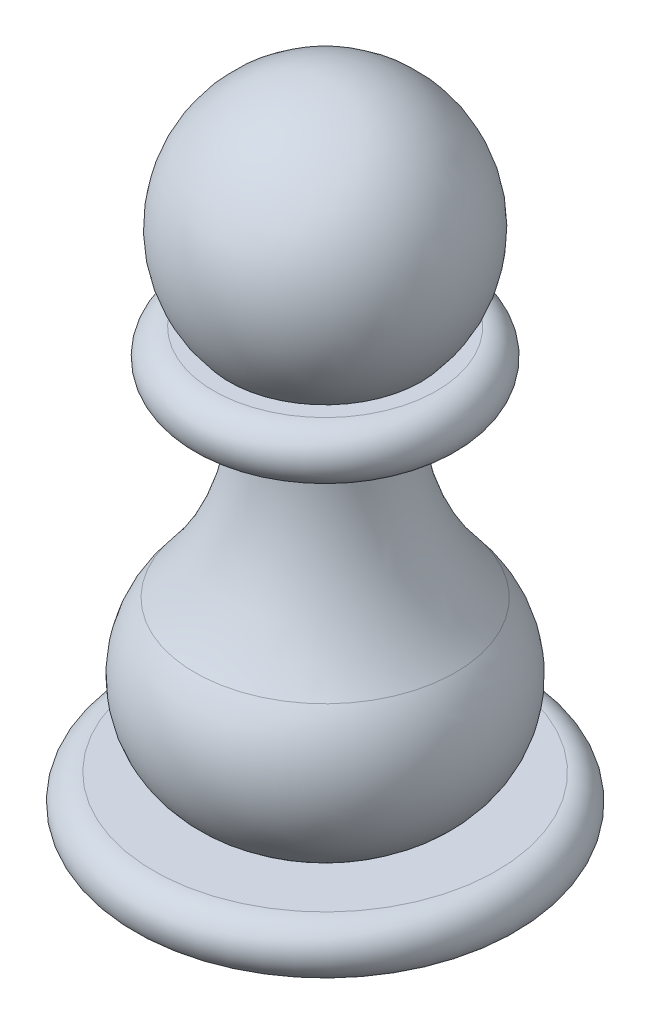
from build123d import *


with BuildPart() as part:
    # Sketch1 → Revolve2 (revolve)
    with BuildSketch(Plane.XY, mode=Mode.PRIVATE) as revolve2_sk:
        with BuildLine():
            Line((-10, 0), (0, 0))
            Line((0, 0), (0, 3))
            Line((0, 3), (-6.5, 3))
            Line((-6.5, 3), (-10, 3))
            ThreePointArc((-10, 3), (-11.5, 1.5), (-10, 0))
        make_face()
        with BuildLine():
            Line((-6.5, 3), (0, 3))
            Line((0, 3), (0, 22.5))
            Line((0, 22.5), (-4, 22.5))
            ThreePointArc((-4, 22.5), (-4.756442138, 16.807641551), (-7.596345767, 11.816639968))
            ThreePointArc((-7.596345767, 11.816639968), (-9, 7.165611038), (-6.5, 3))
        make_face()
        with BuildLine():
            Line((-4, 22.5), (0, 22.5))
            Line((0, 22.5), (0, 25.5))
            Line((0, 25.5), (-5.590169944, 25.5))
            Line((-5.590169944, 25.5), (-6.5, 25.5))
            ThreePointArc((-6.5, 25.5), (-8, 24), (-6.5, 22.5))
            Line((-6.5, 22.5), (-4, 22.5))
        make_face()
        with BuildLine():
            Line((-5.590169944, 25.5), (0, 25.5))
            Line((0, 25.5), (0, 38))
            ThreePointArc((0, 38), (-6.846531969, 33.561862178), (-5.590169944, 25.5))
        make_face()
    revolve(revolve2_sk.sketch.rotate(Axis((0, 0, 0), (0, 1, 0)), 270), axis=Axis((0, 0, 0), (0, 1, 0)))


solid = part.part
